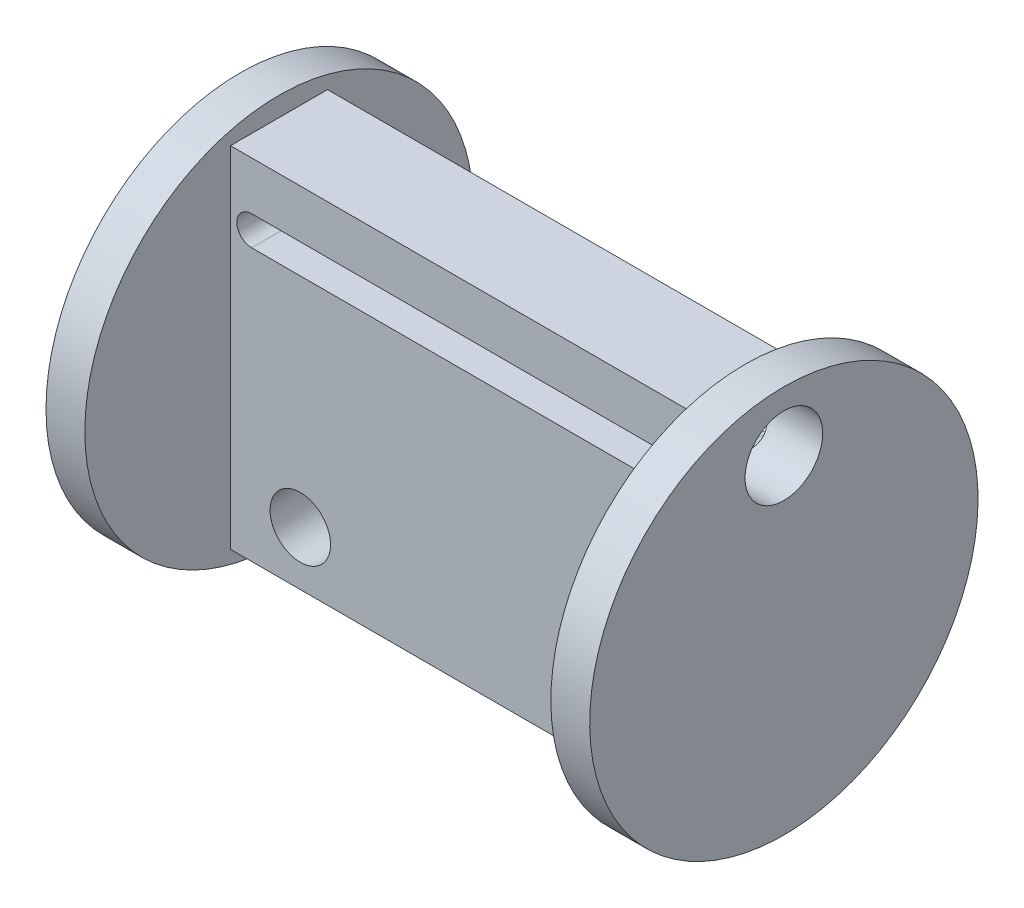
from build123d import *

# Parameters (mm, degrees)
SKETCH1_W           = 24
SKETCH1_H           = 18
BOSS_EXTRUDE1_DEPTH = 5
SKETCH3_R           = 1.5575
CUT_EXTRUDE1_DEPTH  = 6
CUT_EXTRUDE2_DEPTH  = 6
SKETCH5_R           = 10
BOSS_EXTRUDE3_DEPTH = 2
SKETCH6_R           = 10
BOSS_EXTRUDE4_DEPTH = 2
SKETCH7_R           = 2
CUT_EXTRUDE3_DEPTH  = 29


with BuildPart() as part:
    # Sketch1 → Boss-Extrude1 (new body)
    with BuildSketch(Plane.XY):
        with Locations((12, -9)):
            Rectangle(SKETCH1_W, SKETCH1_H)
    extrude(amount=BOSS_EXTRUDE1_DEPTH)

    # Sketch3 → Cut-Extrude1 (cut, through all)
    with BuildSketch(Plane.XY.offset(5)):
        with Locations((3.59586, -15.22505)):
            Circle(SKETCH3_R)
        with Locations((19.14986, -15.22505)):
            Circle(SKETCH3_R)
    extrude(amount=-CUT_EXTRUDE1_DEPTH, mode=Mode.SUBTRACT)

    # Sketch4 → Cut-Extrude2 (cut, through all)
    with BuildSketch(Plane.XY.offset(5)):
        with BuildLine():
            Line((1.089474394, -2.489991356), (22.608748961, -2.489991356))
            ThreePointArc((22.608748961, -2.489991356), (23.368757605, -3.25), (22.608748961, -4.010008644))
            Line((22.608748961, -4.010008644), (1.089474394, -4.010008644))
            ThreePointArc((1.089474394, -4.010008644), (0.32946575, -3.25), (1.089474394, -2.489991356))
        make_face()
    extrude(amount=-CUT_EXTRUDE2_DEPTH, mode=Mode.SUBTRACT)

    # Sketch5 → Boss-Extrude3 (add)
    with BuildSketch(Plane.ZY):
        with Locations((2.5, -9)):
            Circle(SKETCH5_R)
    extrude(amount=BOSS_EXTRUDE3_DEPTH)

    # Sketch6 → Boss-Extrude4 (add)
    with BuildSketch(Plane(origin=(24, 0, 0), x_dir=(0, 0, -1), z_dir=(1, 0, 0))):
        with Locations((-2.5, -9)):
            Circle(SKETCH6_R)
    extrude(amount=BOSS_EXTRUDE4_DEPTH)

    # Sketch7 → Cut-Extrude3 (cut, through all)
    with BuildSketch(Plane(origin=(26, 0, 0), x_dir=(0, 0, -1), z_dir=(1, 0, 0))):
        with Locations((-2.5, -2.07616)):
            Circle(SKETCH7_R)
    extrude(amount=-CUT_EXTRUDE3_DEPTH, mode=Mode.SUBTRACT)


solid = part.part
